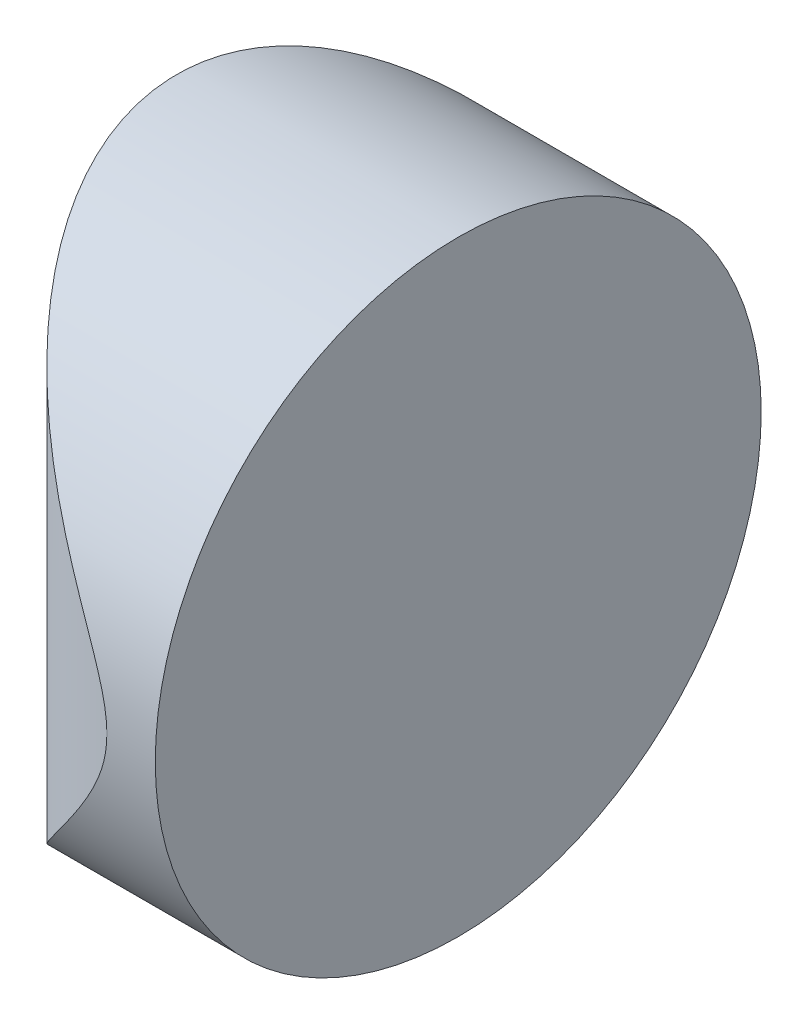
from build123d import *

# Parameters (mm, degrees)
EXTRUDE_1_DEPTH     = 25
CUT_EXTRUDE_8_DEPTH = 12.7


with BuildPart() as part:
    # 草图1 → 凸台-拉伸1 (new body)
    with BuildSketch(Plane(origin=(0, 0, 0), x_dir=(1, 0, 0), z_dir=(0, 1, 0))):
        with BuildLine():
            Line((1.048408302, 12.5), (3.045204335, 12.5))
            Line((3.045204335, 12.5), (3.045204335, -12.5))
            Line((3.045204335, -12.5), (1.048408302, -12.5))
            ThreePointArc((1.048408302, -12.5), (-8.574795665, 0), (1.048408302, 12.5))
        make_face()
    extrude(amount=EXTRUDE_1_DEPTH)

    # 草图2 → 切除-拉伸8 (cut)
    with BuildSketch(Plane(origin=(3.045204335, 0, 0), x_dir=(0, 0, -1), z_dir=(1, 0, 0))):
        with BuildLine():
            Line((-12.5, 25), (-12.5, 12.5))
            ThreePointArc((-12.5, 12.5), (-8.838834765, 21.338834765), (0, 25))
            Line((0, 25), (-12.5, 25))
        make_face()
        with BuildLine():
            ThreePointArc((0, 25), (8.838834765, 21.338834765), (12.5, 12.5))
            Line((12.5, 12.5), (12.5, 25))
            Line((12.5, 25), (0, 25))
        make_face()
        with BuildLine():
            ThreePointArc((12.5, 12.5), (8.838834765, 3.661165235), (0, 0))
            Line((0, 0), (12.5, 0))
            Line((12.5, 0), (12.5, 12.5))
        make_face()
        with BuildLine():
            Line((-12.5, 12.5), (-12.5, 0))
            Line((-12.5, 0), (0, 0))
            ThreePointArc((0, 0), (-8.838834765, 3.661165235), (-12.5, 12.5))
        make_face()
    extrude(amount=-CUT_EXTRUDE_8_DEPTH, mode=Mode.SUBTRACT)


solid = part.part
